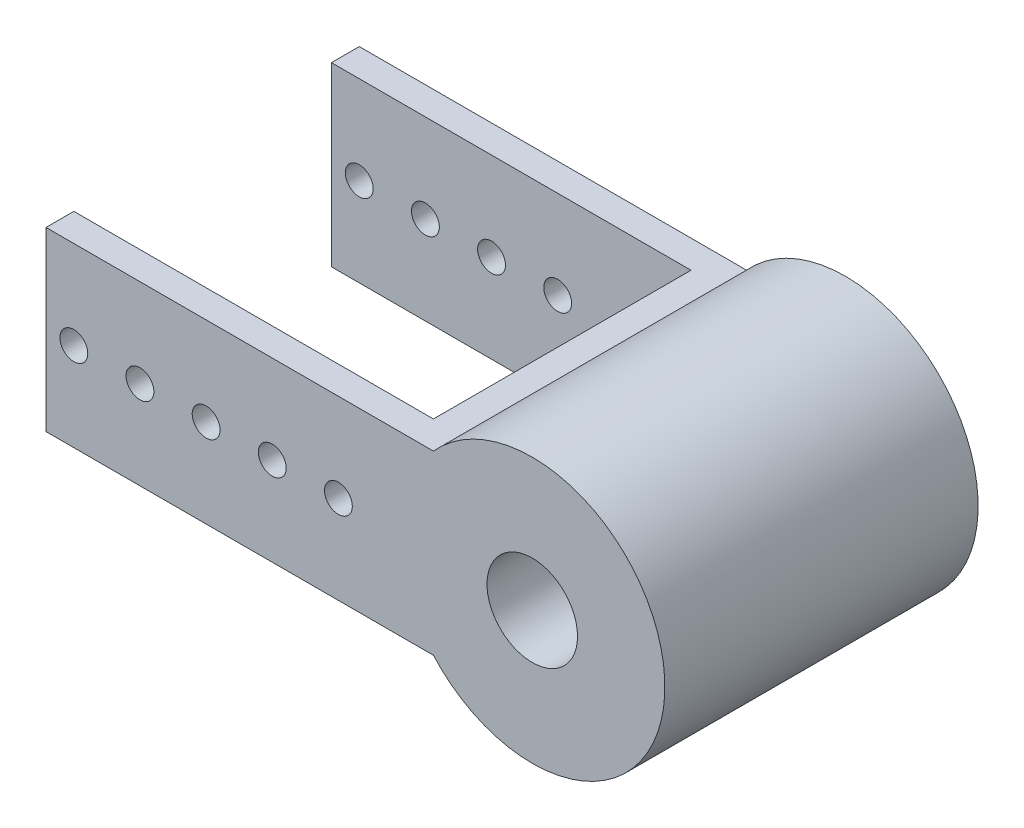
from build123d import *

# Parameters (mm, degrees)
SKETCH1_R               = 13
SKETCH1_R_2             = 4
BOSS_EXTRUDE1_DEPTH     = 45
SKETCH2_W               = 103.301936686
SKETCH2_H               = 74
CUT_EXTRUDE1_DEPTH      = 13.7
CUT_EXTRUDE1_DEPTH_BACK = 64.5


with BuildPart() as part:
    # Sketch1 → Boss-Extrude1 (new body, symmetric)
    with BuildSketch(Plane.XY):
        with BuildLine():
            Line((-28.398063314, 25.4), (-139.7, 25.4))
            Line((-139.7, 25.4), (-139.7, -25.4))
            Line((-139.7, -25.4), (-28.398063314, -25.4))
            ThreePointArc((-28.398063314, -25.4), (38.1, 0), (-28.398063314, 25.4))
        make_face()
        Circle(SKETCH1_R, mode=Mode.SUBTRACT)
        with Locations((-131.7, 0)):
            Circle(SKETCH1_R_2, mode=Mode.SUBTRACT)
        with Locations((-112.7, 0)):
            Circle(SKETCH1_R_2, mode=Mode.SUBTRACT)
        with Locations((-93.7, 0)):
            Circle(SKETCH1_R_2, mode=Mode.SUBTRACT)
        with Locations((-74.7, 0)):
            Circle(SKETCH1_R_2, mode=Mode.SUBTRACT)
        with Locations((-55.7, 0)):
            Circle(SKETCH1_R_2, mode=Mode.SUBTRACT)
    extrude(amount=BOSS_EXTRUDE1_DEPTH, both=True)

    # Sketch2 → Cut-Extrude1 (cut, two sides)
    with BuildSketch(Plane(origin=(0, 25.4, 0), x_dir=(1, 0, 0), z_dir=(0, 1, 0))) as cut_extrude1_sk:
        with Locations((-88.049031657, 0)):
            Rectangle(SKETCH2_W, SKETCH2_H)
    extrude(amount=CUT_EXTRUDE1_DEPTH, mode=Mode.SUBTRACT)
    extrude(cut_extrude1_sk.sketch, amount=-CUT_EXTRUDE1_DEPTH_BACK, mode=Mode.SUBTRACT)


solid = part.part
